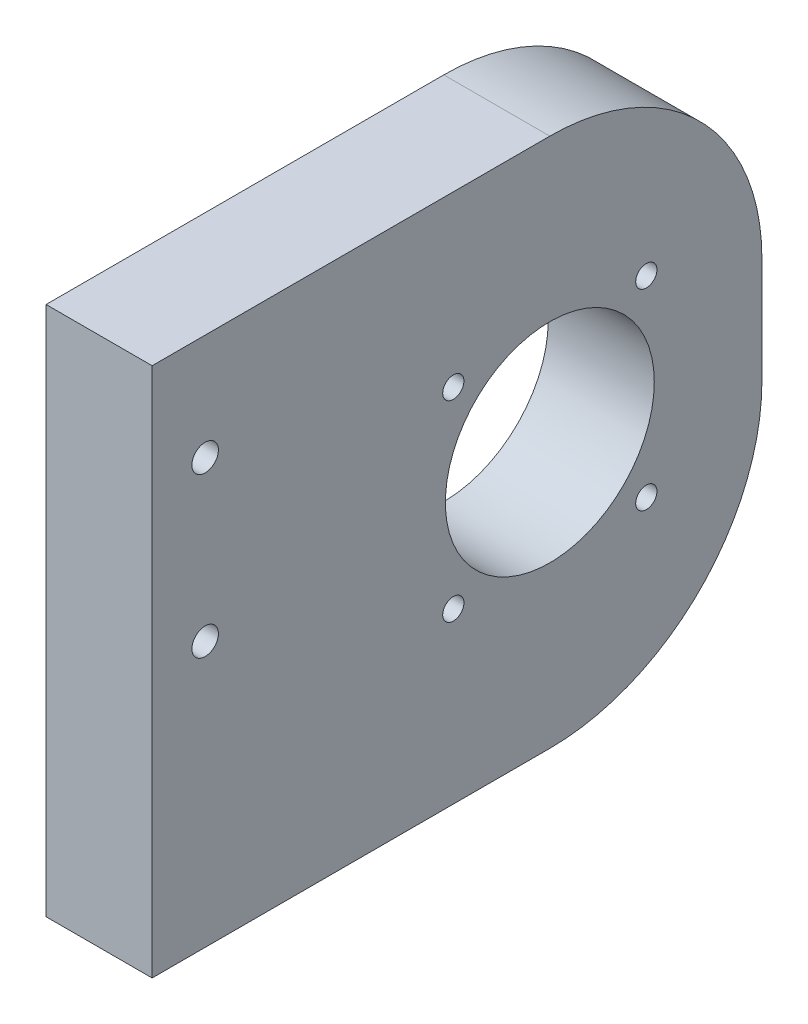
from build123d import *

# Parameters (mm, degrees)
SKETCH1_W           = 25.4
SKETCH1_H           = 127
BOSS_EXTRUDE1_DEPTH = 146.05
FILLET1_R           = 50.8
SKETCH3_R           = 3.175
SKETCH3_R_2         = 25.019
SKETCH3_R_3         = 2.54
CUT_EXTRUDE1_DEPTH  = 25.4


with BuildPart() as part:
    # Sketch1 → Boss-Extrude1 (new body)
    with BuildSketch(Plane.XY):
        with Locations((12.7, 63.5)):
            Rectangle(SKETCH1_W, SKETCH1_H)
    extrude(amount=BOSS_EXTRUDE1_DEPTH)

    # Fillet1
    fillet1_edges = [part.edges().sort_by_distance(p)[0] for p in [
        (12.7, 127, 0),
        (12.7, 0, 0),
    ]]
    fillet(fillet1_edges, radius=FILLET1_R)

    # Sketch3 → Cut-Extrude1 (cut)
    with BuildSketch(Plane(origin=(25.4, 0, 0), x_dir=(0, 0, -1), z_dir=(1, 0, 0))):
        with Locations((-133.35, 63.5)):
            Circle(SKETCH3_R)
        with Locations((-133.35, 101.6)):
            Circle(SKETCH3_R)
        with Locations((-50.8, 63.5)):
            Circle(SKETCH3_R_2)
        with Locations((-73.914, 86.487)):
            Circle(SKETCH3_R_3)
        with Locations((-27.686, 86.487)):
            Circle(SKETCH3_R_3)
        with Locations((-27.686, 40.513)):
            Circle(SKETCH3_R_3)
        with Locations((-73.914, 40.513)):
            Circle(SKETCH3_R_3)
    extrude(amount=-CUT_EXTRUDE1_DEPTH, mode=Mode.SUBTRACT)


solid = part.part
